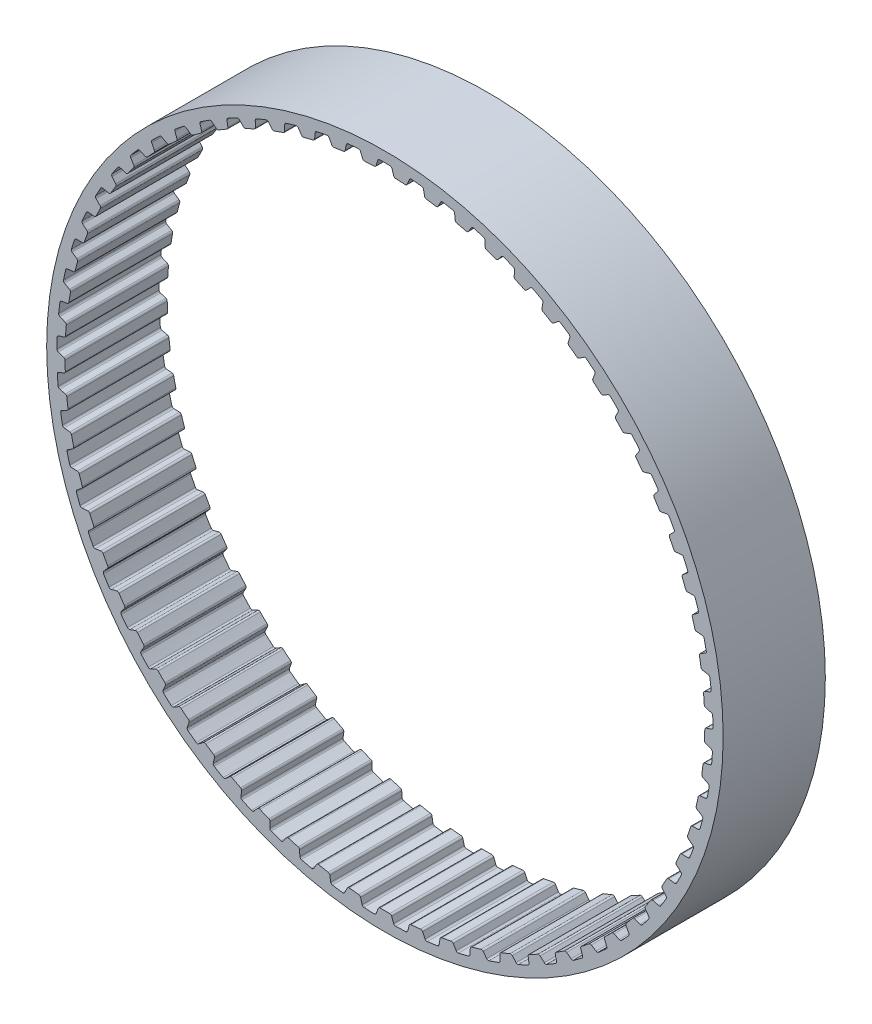
from build123d import *

# Parameters (mm, degrees)
SKETCH1_R           = 21.021202639
SKETCH1_R_2         = 19.878202639
BOSS_EXTRUDE1_DEPTH = 3.175
CUT_EXTRUDE1_DEPTH  = 3.175
CIRPATTERN1_COUNT   = 65


with BuildPart() as part:
    # Sketch1 → Boss-Extrude1 (new body, symmetric)
    with BuildSketch(Plane.XY):
        Circle(SKETCH1_R)
        Circle(SKETCH1_R_2, mode=Mode.SUBTRACT)
    extrude(amount=BOSS_EXTRUDE1_DEPTH, both=True)

    # Sketch3 → Cut-Extrude1 (cut, symmetric)
    with BuildSketch(Plane.XY):
        with BuildLine():
            Line((-0.662084056, 19.86717355), (0.662084056, 19.86717355))
            ThreePointArc((0.662084056, 19.86717355), (0.589284831, 19.89313032), (0.545013884, 19.956483018))
            Line((0.545013884, 19.956483018), (0.440239495, 20.294312032))
            ThreePointArc((0.440239495, 20.294312032), (0.39507856, 20.358337511), (0.320938681, 20.383676224))
            ThreePointArc((0.320938681, 20.383676224), (0, 20.386202639), (-0.320938681, 20.383676224))
            ThreePointArc((-0.320938681, 20.383676224), (-0.39507856, 20.358337511), (-0.440239495, 20.294312032))
            Line((-0.440239495, 20.294312032), (-0.545013884, 19.956483018))
            ThreePointArc((-0.545013884, 19.956483018), (-0.589284831, 19.89313032), (-0.662084056, 19.86717355))
        make_face()
    cut_extrude1 = extrude(amount=CUT_EXTRUDE1_DEPTH, both=True, mode=Mode.SUBTRACT)

    # CirPattern1: Cut-Extrude1 ×65 about axis
    cirpattern1_axis = Axis((0, 0, 0), (0, 0, 1))
    for i in range(1, CIRPATTERN1_COUNT):
        add(cut_extrude1.rotate(cirpattern1_axis, i * 360 / CIRPATTERN1_COUNT), mode=Mode.SUBTRACT)


solid = part.part
